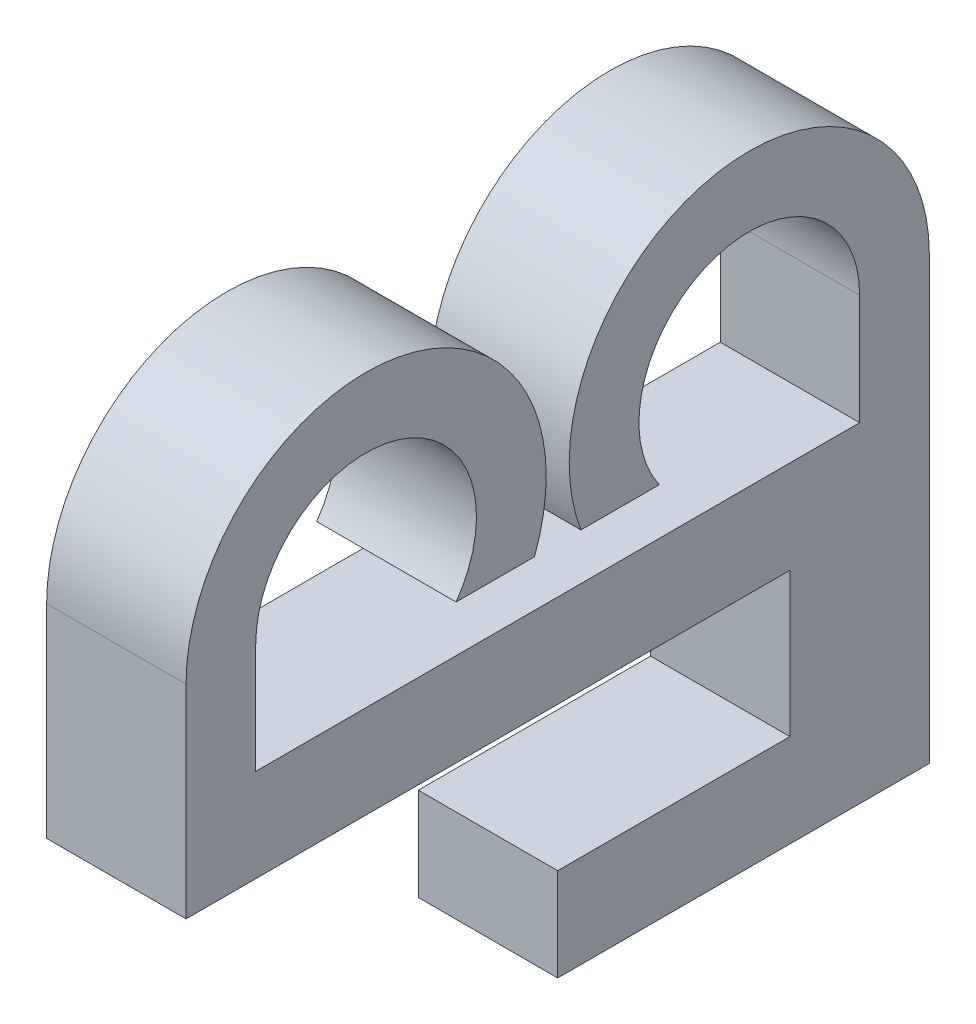
from build123d import *

# Parameters (mm, degrees)
BOSS_EXTRUDE1_DEPTH = 3
BOSS_EXTRUDE2_DEPTH = 3


with BuildPart() as part:
    # Sketch1 → Boss-Extrude1 (new body)
    with BuildSketch(Plane(origin=(0, 0, 0), x_dir=(0, 0, -1), z_dir=(1, 0, 0))):
        with BuildLine():
            Line((-7.997844187, 2.375), (-7.997844187, -2))
            Line((-7.997844187, -2), (7.997844187, -2))
            Line((7.997844187, -2), (7.997844187, 2.375))
            ThreePointArc((7.997844187, 2.375), (3.423879317, 6.186439769), (0.5, 1))
            Line((0.5, 1), (2.186352513, 1))
            ThreePointArc((2.186352513, 1), (3.401228889, 4.637718799), (6.497844187, 2.375))
            Line((6.497844187, 2.375), (6.497844187, 0))
            Line((6.497844187, 0), (-6.497844187, 0))
            Line((-6.497844187, 0), (-6.497844187, 2.375))
            ThreePointArc((-6.497844187, 2.375), (-3.401228889, 4.637718799), (-2.186352513, 1))
            Line((-2.186352513, 1), (-0.5, 1))
            ThreePointArc((-0.5, 1), (-3.423879317, 6.186439769), (-7.997844187, 2.375))
        make_face()
    extrude(amount=BOSS_EXTRUDE1_DEPTH)

    # Sketch2 → Boss-Extrude2 (add)
    with BuildSketch(Plane.ZY):
        Polygon((-7.997844187, -2), (-7.997844187, -7.1), (0, -7.1), (0, -5.1), (-4.997844187, -5.1), (-4.997844187, -2), align=None)
    extrude(amount=-BOSS_EXTRUDE2_DEPTH)


solid = part.part
